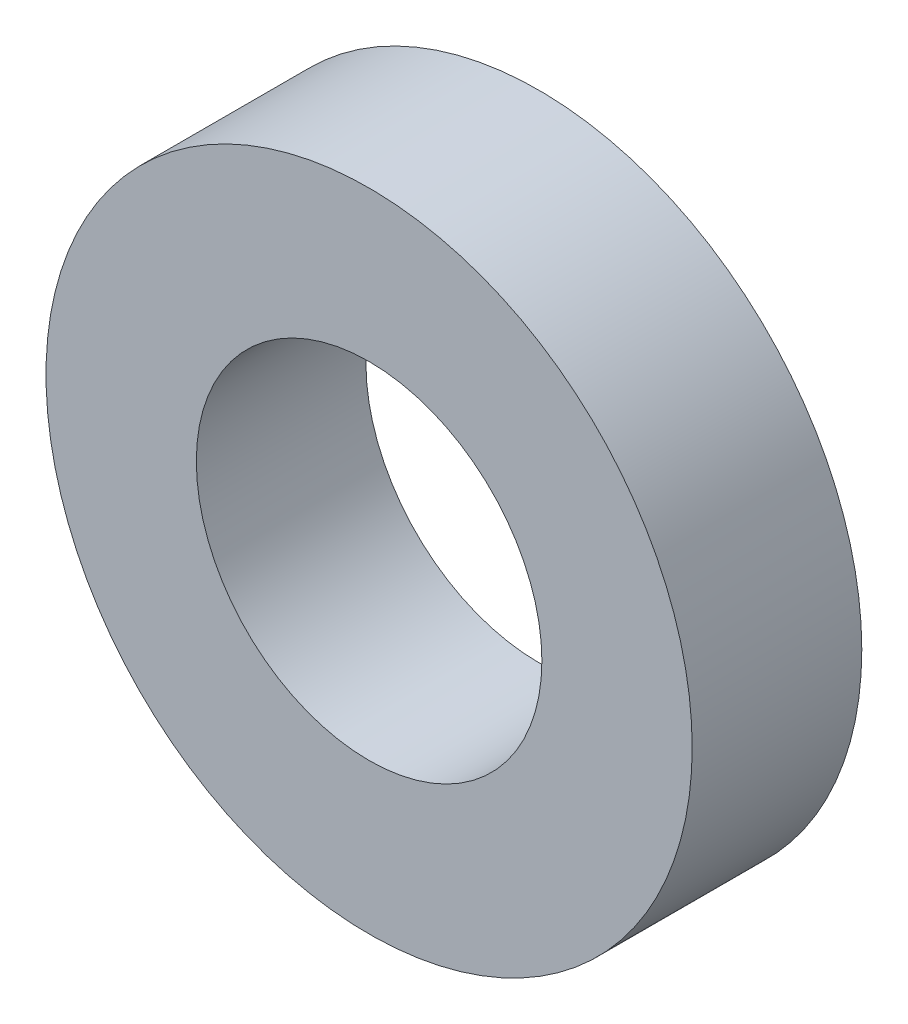
from build123d import *

# Parameters (mm, degrees)
SKETCH1_R           = 38.1
SKETCH1_R_2         = 20.375
BOSS_EXTRUDE1_DEPTH = 20


with BuildPart() as part:
    # Sketch1 → Boss-Extrude1 (new body)
    with BuildSketch(Plane.XY):
        Circle(SKETCH1_R)
        Circle(SKETCH1_R_2, mode=Mode.SUBTRACT)
    extrude(amount=BOSS_EXTRUDE1_DEPTH)


solid = part.part
